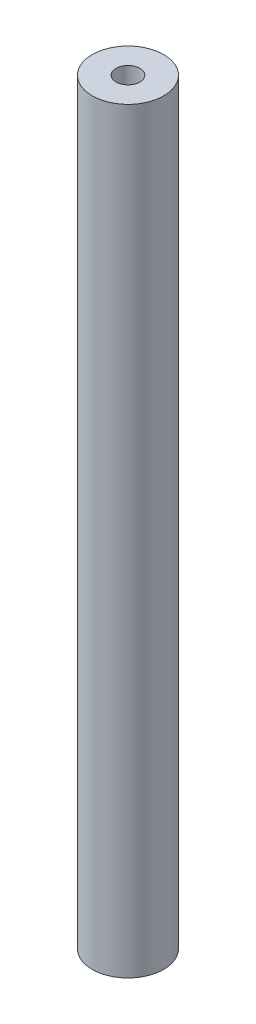
from build123d import *

# Parameters (mm, degrees)
SKETCH_1_R      = 3
SKETCH_1_R_2    = 1
EXTRUDE_1_DEPTH = 63.5


with BuildPart() as part:
    # 草图1 → 凸台-拉伸1 (new body)
    with BuildSketch(Plane(origin=(0, 0, 0), x_dir=(1, 0, 0), z_dir=(0, 1, 0))):
        Circle(SKETCH_1_R)
        Circle(SKETCH_1_R_2, mode=Mode.SUBTRACT)
    extrude(amount=EXTRUDE_1_DEPTH)


solid = part.part
